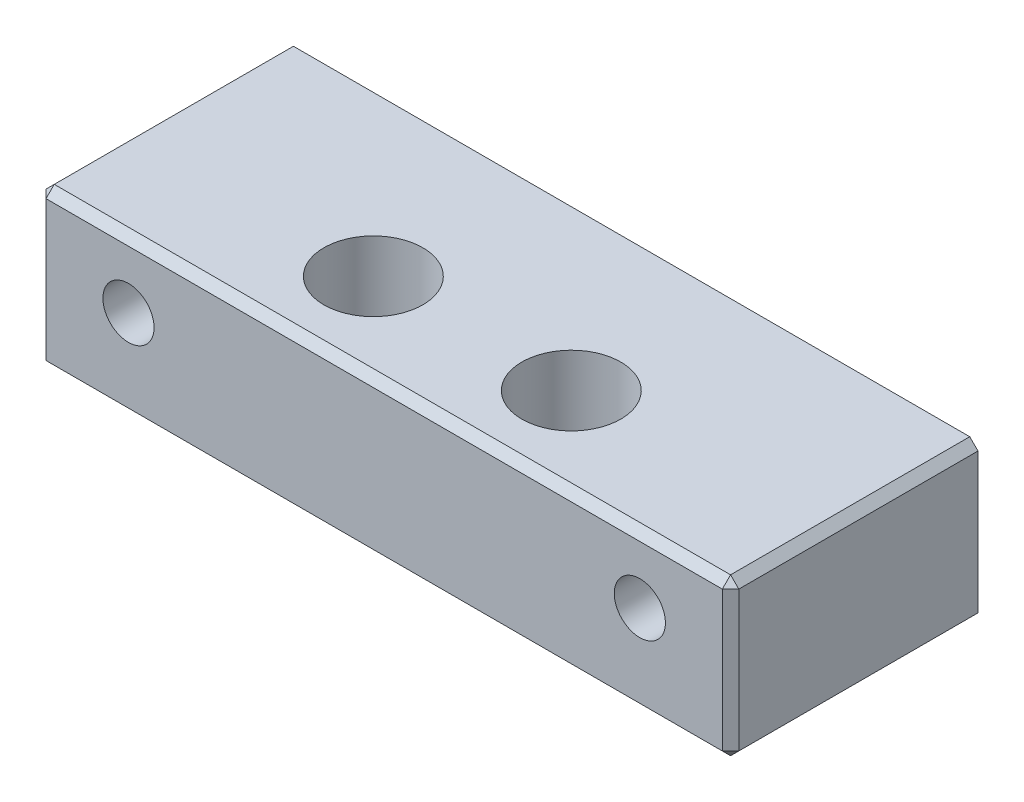
from build123d import *

# Parameters (mm, degrees)
SKETCH1_W           = 42
SKETCH1_H           = 9.5
BOSS_EXTRUDE1_DEPTH = 7.5
SKETCH2_R           = 1.55
CUT_EXTRUDE1_DEPTH  = 16
SKETCH4_R           = 3
CUT_EXTRUDE2_DEPTH  = 10.5
CHAMFER3_SIZE       = 0.5


with BuildPart() as part:
    # Sketch1 → Boss-Extrude1 (new body, symmetric)
    with BuildSketch(Plane.XY):
        Rectangle(SKETCH1_W, SKETCH1_H)
    extrude(amount=BOSS_EXTRUDE1_DEPTH, both=True)

    # Sketch2 → Cut-Extrude1 (cut, through all)
    with BuildSketch(Plane.XY.offset(7.5)):
        with Locations((-15.5, 0.75)):
            Circle(SKETCH2_R)
        with Locations((15.5, 0.75)):
            Circle(SKETCH2_R)
    extrude(amount=-CUT_EXTRUDE1_DEPTH, mode=Mode.SUBTRACT)

    # Sketch4 → Cut-Extrude2 (cut, through all)
    with BuildSketch(Plane(origin=(0, 4.75, 0), x_dir=(1, 0, 0), z_dir=(0, 1, 0))):
        with Locations((6, -2.155)):
            Circle(SKETCH4_R)
        with Locations((-6, -2.155)):
            Circle(SKETCH4_R)
    extrude(amount=-CUT_EXTRUDE2_DEPTH, mode=Mode.SUBTRACT)

    # Chamfer3
    chamfer3_edges = [part.edges().sort_by_distance(p)[0] for p in [
        (-21, 0, 7.5),
        (0, -4.75, 7.5),
        (21, 0, 7.5),
        (0, 4.75, 7.5),
        (21, -4.75, 0),
        (-21, -4.75, 0),
        (-21, 4.75, 0),
        (21, 4.75, 0),
    ]]
    chamfer(chamfer3_edges, length=CHAMFER3_SIZE)


solid = part.part
